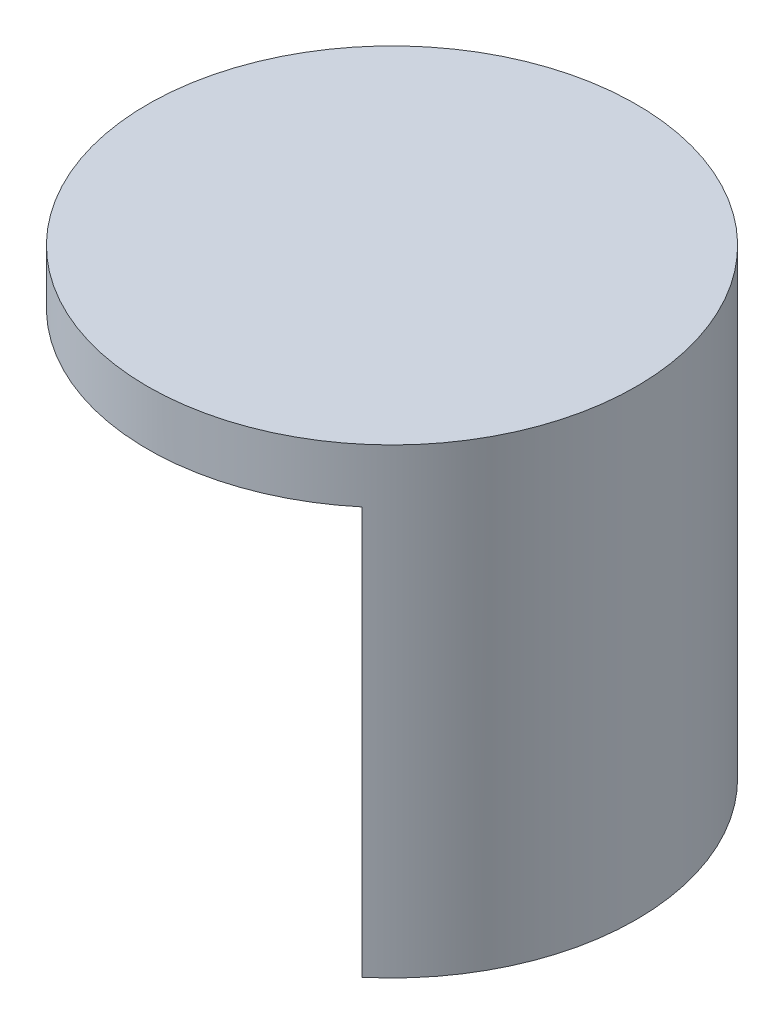
from build123d import *

# Parameters (mm, degrees)
SKIZZE1_R                       = 18
AUFSATZ_LINEAR_AUSTRAGEN1_DEPTH = 4
AUFSATZ_LINEAR_AUSTRAGEN2_DEPTH = 30


with BuildPart() as part:
    # Skizze1 → Aufsatz-Linear austragen1 (new body)
    with BuildSketch(Plane(origin=(0, 0, 0), x_dir=(1, 0, 0), z_dir=(0, 1, 0))):
        Circle(SKIZZE1_R)
    extrude(amount=AUFSATZ_LINEAR_AUSTRAGEN1_DEPTH)

    # Skizze2 → Aufsatz-Linear austragen2 (add)
    with BuildSketch(Plane.XZ):
        with BuildLine():
            Line((11.570176974, 13.788799976), (8.356238926, 9.958577761))
            ThreePointArc((8.356238926, 9.958577761), (11.782001231, 5.494037403), (13, 0))
            ThreePointArc((13, 0), (11.782001231, -5.494037403), (8.356238926, -9.958577761))
            Line((8.356238926, -9.958577761), (11.570176974, -13.788799976))
            ThreePointArc((11.570176974, -13.788799976), (16.313540167, -7.607128711), (18, 0))
            ThreePointArc((18, 0), (16.313540167, 7.607128711), (11.570176974, 13.788799976))
        make_face()
    extrude(amount=AUFSATZ_LINEAR_AUSTRAGEN2_DEPTH)


solid = part.part
